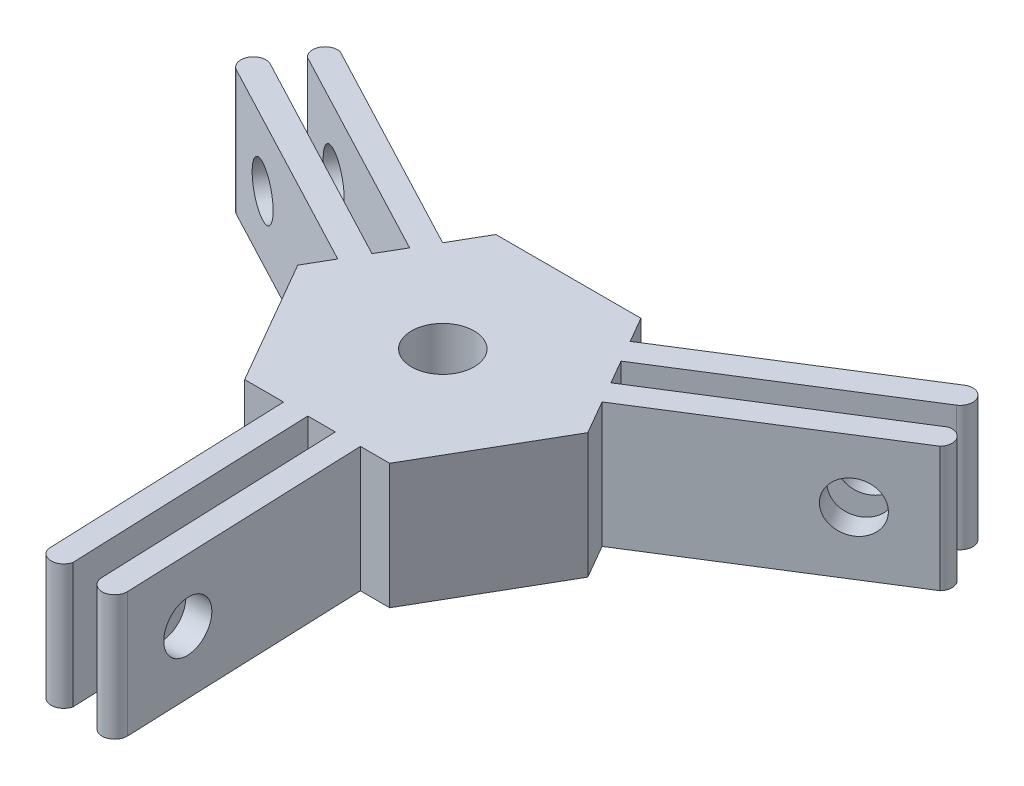
from build123d import *

# Parameters (mm, degrees)
SKETCH1_R           = 2.5
BOSS_EXTRUDE1_DEPTH = 10
SKETCH2_R           = 2
CUT_EXTRUDE1_DEPTH  = 10
CIRPATTERN1_COUNT   = 3
SKETCH3_R           = 2.5
BOSS_EXTRUDE3_DEPTH = 10


with BuildPart() as part:
    # Sketch1 → Boss-Extrude1 (new body)
    with BuildSketch(Plane(origin=(0, 0, 0), x_dir=(1, 0, 0), z_dir=(0, 1, 0))):
        with BuildLine():
            Line((3.42943918, -9.393558799), (4.197898245, -29.378790113))
            ThreePointArc((4.197898245, -29.378790113), (3.237059632, -30.416474632), (2.199375114, -29.455636019))
            Line((2.199375114, -29.455636019), (1.447231615, -9.894721858))
            ThreePointArc((1.447231615, -9.894721858), (0.350023332, -9.993872306), (-0.751433173, -9.971727442))
            Line((-0.751433173, -9.971727442), (0.000999669, -29.540166516))
            ThreePointArc((0.000999669, -29.540166516), (-0.935779597, -30.318112399), (-1.929530696, -29.614398009))
            Line((-1.929530696, -29.614398009), (-2.697989761, -9.629166695))
            ThreePointArc((-2.697989761, -9.629166695), (-8.461744243, -5.329060364), (-9.849780142, 1.726797949))
            Line((-9.849780142, 1.726797949), (-27.541727692, 11.053908534))
            ThreePointArc((-27.541727692, 11.053908534), (-27.959969541, 12.404861441), (-26.609016634, 12.823103289))
            Line((-26.609016634, 12.823103289), (-9.2926963, 3.694021585))
            ThreePointArc((-9.2926963, 3.694021585), (-8.829958965, 4.693807055), (-8.260052699, 5.636623938))
            Line((-8.260052699, 5.636623938), (-25.58303447, 14.769217519))
            ThreePointArc((-25.58303447, 14.769217519), (-25.788365734, 15.969465103), (-24.682055646, 16.478221605))
            Line((-24.682055646, 16.478221605), (-6.990108095, 7.15111102))
            ThreePointArc((-6.990108095, 7.15111102), (-0.384229532, 9.992615657), (6.420340962, 7.66676085))
            Line((6.420340962, 7.66676085), (23.343829448, 18.324881579))
            ThreePointArc((23.343829448, 18.324881579), (24.722909908, 18.011613191), (24.40964152, 16.63253273))
            Line((24.40964152, 16.63253273), (7.845464685, 6.200700273))
            ThreePointArc((7.845464685, 6.200700273), (8.479935633, 5.300065251), (9.011485871, 4.335103505))
            Line((9.011485871, 4.335103505), (25.582034801, 14.770948997))
            ThreePointArc((25.582034801, 14.770948997), (26.724145331, 14.348647296), (26.611586342, 13.136176404))
            Line((26.611586342, 13.136176404), (9.688097856, 2.478055676))
            ThreePointArc((9.688097856, 2.478055676), (8.845973775, -4.663555293), (3.42943918, -9.393558799))
        make_face()
        Circle(SKETCH1_R, mode=Mode.SUBTRACT)
    extrude(amount=BOSS_EXTRUDE1_DEPTH)

    # Sketch2 → Cut-Extrude1 (cut)
    with BuildSketch(Plane(origin=(3.063714471, 0, -0.117803948), x_dir=(-0.038422953, 0, -0.999261566), z_dir=(0.999261566, 0, -0.038422953))):
        with Locations((-24.518391454, 5)):
            Circle(SKETCH2_R)
    cut_extrude1 = extrude(amount=-CUT_EXTRUDE1_DEPTH, mode=Mode.SUBTRACT)

    # CirPattern1: Cut-Extrude1 ×3 about axis
    cirpattern1_axis = Axis((0, 10, 0), (0, -1, 0))
    for i in range(1, CIRPATTERN1_COUNT):
        add(cut_extrude1.rotate(cirpattern1_axis, i * 360 / CIRPATTERN1_COUNT), mode=Mode.SUBTRACT)

    # Sketch3 → Boss-Extrude3 (add)
    with BuildSketch(Plane(origin=(0, 10, 0), x_dir=(1, 0, 0), z_dir=(0, 1, 0))):
        Polygon((11.5901527, 0), (5.79507635, 10.037366672), (-5.79507635, 10.037366672), (-11.5901527, 0), (-5.79507635, -10.037366672), (5.79507635, -10.037366672), align=None)
        Circle(SKETCH3_R, mode=Mode.SUBTRACT)
    extrude(amount=-BOSS_EXTRUDE3_DEPTH)


solid = part.part
